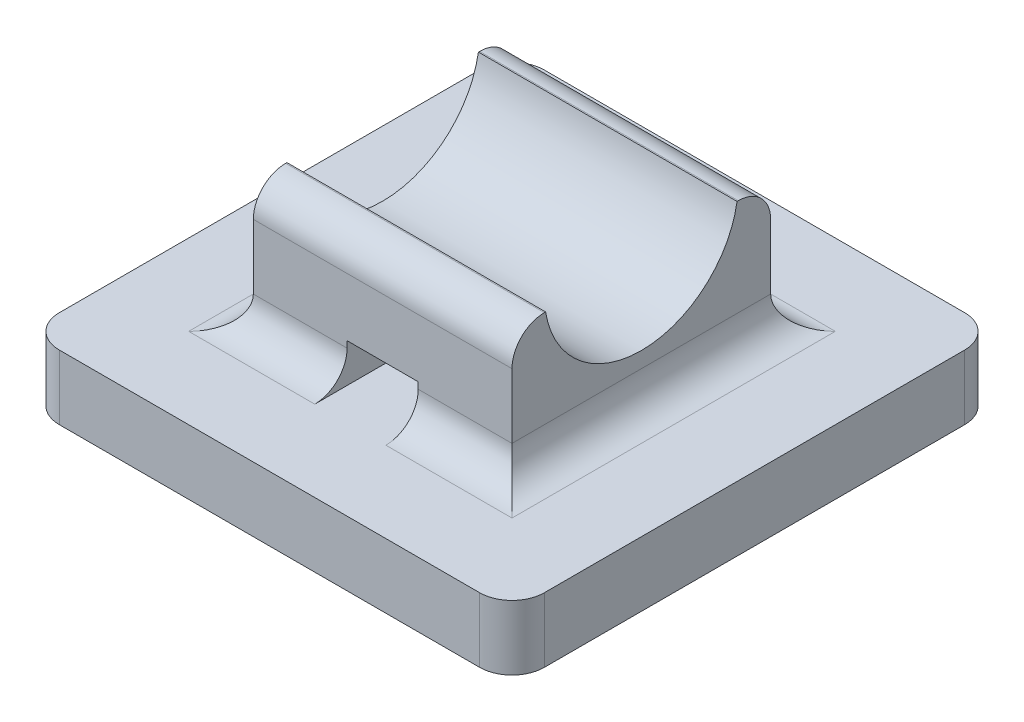
from build123d import *

# Parameters (mm, degrees)
CROQUIS1_W              = 15
CROQUIS1_H              = 15
SALIENTE_EXTRUIR1_DEPTH = 2
CROQUIS2_W              = 8
CROQUIS2_H              = 8
SALIENTE_EXTRUIR2_DEPTH = 4
CROQUIS3_R              = 3
CORTAR_EXTRUIR1_DEPTH   = 8
CROQUIS4_W              = 2.2
CROQUIS4_H              = 1.2
CORTAR_EXTRUIR3_DEPTH   = 8
REDONDEO1_R             = 1


with BuildPart() as part:
    # Croquis1 → Saliente-Extruir1 (new body)
    with BuildSketch(Plane(origin=(0, 0, 0), x_dir=(1, 0, 0), z_dir=(0, 1, 0))):
        with Locations((7.5, 7.5)):
            Rectangle(CROQUIS1_W, CROQUIS1_H)
    extrude(amount=SALIENTE_EXTRUIR1_DEPTH)

    # Croquis2 → Saliente-Extruir2 (add)
    with BuildSketch(Plane(origin=(0, 2, 0), x_dir=(1, 0, 0), z_dir=(0, 1, 0))):
        with Locations((7.5, 7.5)):
            Rectangle(CROQUIS2_W, CROQUIS2_H)
    extrude(amount=SALIENTE_EXTRUIR2_DEPTH)

    # Croquis3 → Cortar-Extruir1 (cut)
    with BuildSketch(Plane(origin=(11.5, 0, 0), x_dir=(0, 0, -1), z_dir=(1, 0, 0))):
        with Locations((7.5, 6.485438982)):
            Circle(CROQUIS3_R)
    extrude(amount=-CORTAR_EXTRUIR1_DEPTH, mode=Mode.SUBTRACT)

    # Croquis4 → Cortar-Extruir3 (cut)
    with BuildSketch(Plane.XY.offset(-3.5)):
        with Locations((7.5, 2.6)):
            Rectangle(CROQUIS4_W, CROQUIS4_H)
    extrude(amount=-CORTAR_EXTRUIR3_DEPTH, mode=Mode.SUBTRACT)

    # Redondeo1
    redondeo1_edges = [part.edges().sort_by_distance(p)[0] for p in [
        (11.5, 2, -7.5),
        (10.05, 2, -11.5),
        (3.5, 2, -7.5),
        (4.95, 2, -3.5),
        (7.5, 6, -11.5),
        (7.5, 6, -3.5),
        (10.05, 2, -3.5),
        (4.95, 2, -11.5),
        (0, 1, -15),
        (15, 1, -15),
        (15, 1, 0),
        (0, 1, 0),
    ]]
    fillet(redondeo1_edges, radius=REDONDEO1_R)


solid = part.part
